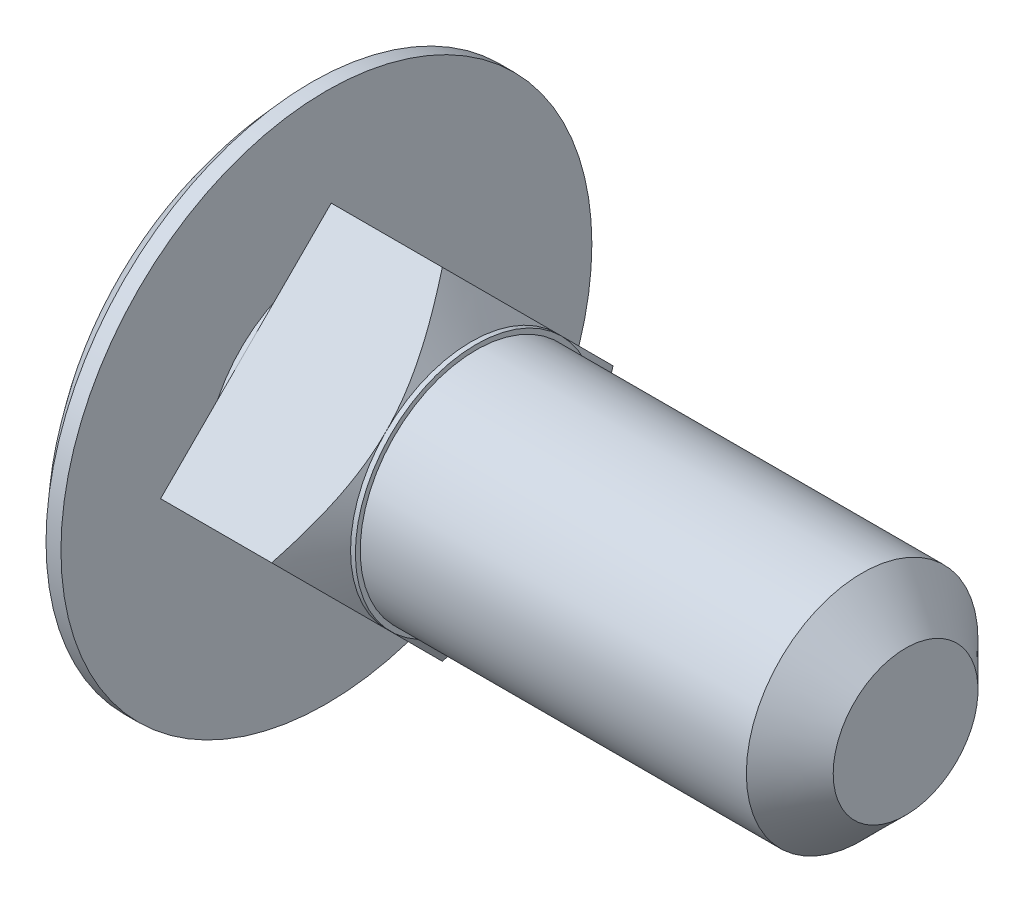
from build123d import *

# Parameters (mm, degrees)
EXTRUDE_START       = 0.1
EXTRUDE_1_DEPTH     = 2.9
SKETCH_6_R          = 2.5
SKETCH_6_R_2        = 2.4
CUT_EXTRUDE_1_DEPTH = 8.9


with BuildPart() as part:
    # Эскиз3 → Повернуть1 (revolve)
    with BuildSketch(Plane.XY):
        with BuildLine():
            Line((12, 0), (12, 1.5))
            Line((12, 1.5), (11, 2.5))
            Line((11, 2.5), (0, 2.5))
            Line((0, 2.5), (0, 5.5))
            Line((0, 5.5), (-0.309475019, 5.5))
            ThreePointArc((-0.309475019, 5.5), (-1.9322204, 2.960084445), (-2.5, 0))
            Line((-2.5, 0), (12, 0))
        make_face()
    revolve(axis=Axis((-123.766149148, 0, 0), (1, 0, 0)))

    # Эскиз4 → Бобышка-Вытянуть1 (add)
    with BuildSketch(Plane(origin=(0, 0, 0), x_dir=(0, 0, -1), z_dir=(1, 0, 0)).offset(EXTRUDE_START)):
        Polygon((0, 3.535533906), (-3.535533906, 0), (0, -3.535533906), (3.535533906, 0), align=None)
    extrude(amount=EXTRUDE_1_DEPTH)


with BuildPart() as body_2:
    # Эскиз5 → Повернуть2 (revolve)
    with BuildSketch(Plane.XY):
        Polygon((3, 2.5), (2.402134221, 3.535533906), (3, 3.535533906), align=None)
    revolve(axis=Axis((-123.766149148, 0, 0), (1, 0, 0)))


with BuildPart() as part_1:
    add(part.part)

    # Combine 1: cut body 2
    add(body_2.part, mode=Mode.SUBTRACT)

    # Эскиз6 → Вырез-Вытянуть1 (cut)
    with BuildSketch(Plane(origin=(12, 0, 0), x_dir=(0, 0, -1), z_dir=(1, 0, 0))):
        Circle(SKETCH_6_R)
        Circle(SKETCH_6_R_2, mode=Mode.SUBTRACT)
    extrude(amount=-CUT_EXTRUDE_1_DEPTH, mode=Mode.SUBTRACT)


solid = part_1.part
